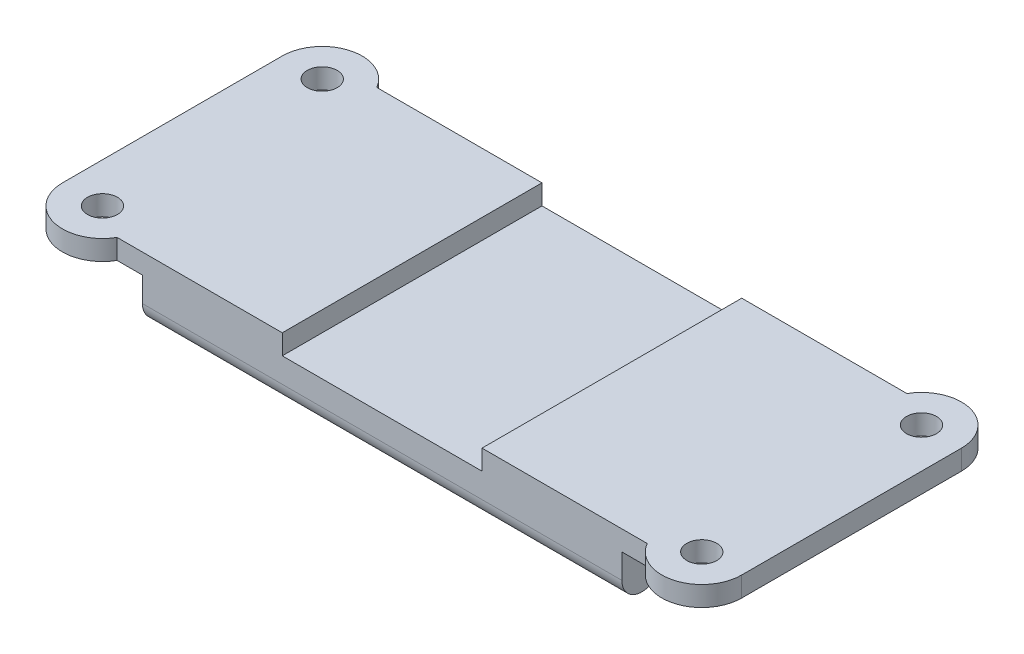
from build123d import *

# Parameters (mm, degrees)
SKETCH1_W               = 48
SKETCH1_H               = 26
BOSS_EXTRUDE1_DEPTH     = 8
CUT_EXTRUDE1_DEPTH      = 1
CUT_EXTRUDE1_DEPTH_BACK = 49
FILLET1_R               = 2
SKETCH5_W               = 26
SKETCH5_H               = 2
BOSS_EXTRUDE2_DEPTH     = 10
SKETCH6_R               = 1.5
CUT_EXTRUDE2_DEPTH      = 10
SKETCH3_W               = 10
SKETCH3_H               = 2
CUT_EXTRUDE3_DEPTH      = 27
FILLET3_R               = 2
SKETCH7_R               = 4
SKETCH7_R_2             = 1.5
BOSS_EXTRUDE3_DEPTH     = 2


with BuildPart() as part:
    # Sketch1 → Boss-Extrude1 (new body)
    with BuildSketch(Plane(origin=(0, 0, 0), x_dir=(1, 0, 0), z_dir=(0, 1, 0))):
        Rectangle(SKETCH1_W, SKETCH1_H)
    extrude(amount=-BOSS_EXTRUDE1_DEPTH)

    # Sketch2 → Cut-Extrude1 (cut, two sides)
    with BuildSketch(Plane(origin=(24, 0, 0), x_dir=(0, 0, -1), z_dir=(1, 0, 0))) as cut_extrude1_sk:
        Polygon((-8, -5), (-13, -8), (0, -8), (0, -5), align=None)
        Polygon((0, -5), (0, -8), (13, -8), (8, -5), align=None)
    extrude(amount=CUT_EXTRUDE1_DEPTH, mode=Mode.SUBTRACT)
    extrude(cut_extrude1_sk.sketch, amount=-CUT_EXTRUDE1_DEPTH_BACK, mode=Mode.SUBTRACT)

    # Fillet1
    fillet1_edges = [part.edges().sort_by_distance(p)[0] for p in [
        (0, -8, -13),
        (0, -5, 8),
        (0, -5, -8),
        (0, -8, 13),
    ]]
    fillet(fillet1_edges, radius=FILLET1_R)

    # Sketch5 → Boss-Extrude2 (add)
    with BuildSketch(Plane.ZY.offset(24)):
        with Locations((0, -1)):
            Rectangle(SKETCH5_W, SKETCH5_H)
    boss_extrude2 = extrude(amount=BOSS_EXTRUDE2_DEPTH)

    # Mirror1: Boss-Extrude2 across plane
    add(boss_extrude2.mirror(Plane(origin=(0, 0, 0), x_dir=(0, 0, 1), z_dir=(1, 0, 0))))

    # Sketch6 → Cut-Extrude2 (cut)
    with BuildSketch(Plane(origin=(0, 0, 0), x_dir=(1, 0, 0), z_dir=(0, 1, 0))):
        with Locations((-30, 11)):
            Circle(SKETCH6_R)
        with Locations((-30, -11)):
            Circle(SKETCH6_R)
        with Locations((30, -11)):
            Circle(SKETCH6_R)
        with Locations((30, 11)):
            Circle(SKETCH6_R)
    extrude(amount=-CUT_EXTRUDE2_DEPTH, mode=Mode.SUBTRACT)

    # Sketch3 → Cut-Extrude3 (cut, through all)
    with BuildSketch(Plane.XY.offset(13)):
        with Locations((5, -1)):
            Rectangle(SKETCH3_W, SKETCH3_H)
        with Locations((-5, -1)):
            Rectangle(SKETCH3_W, SKETCH3_H)
    extrude(amount=-CUT_EXTRUDE3_DEPTH, mode=Mode.SUBTRACT)

    # Fillet3
    fillet3_edges = [part.edges().sort_by_distance(p)[0] for p in [
        (-34, -1, -13),
        (-34, -1, 13),
        (34, -1, -13),
        (34, -1, 13),
    ]]
    fillet(fillet3_edges, radius=FILLET3_R)

    # Sketch7 → Boss-Extrude3 (add)
    with BuildSketch(Plane(origin=(0, 0, 0), x_dir=(1, 0, 0), z_dir=(0, 1, 0))):
        with BuildLine():
            Line((-32, 13), (-26.535898385, 13))
            ThreePointArc((-26.535898385, 13), (-31.03527618, 14.863703305), (-34, 11))
            ThreePointArc((-34, 11), (-33.414213562, 12.414213562), (-32, 13))
        make_face()
        with BuildLine():
            ThreePointArc((-34, -11), (-31.03527618, -14.863703305), (-26.535898385, -13))
            Line((-26.535898385, -13), (-32, -13))
            ThreePointArc((-32, -13), (-33.414213562, -12.414213562), (-34, -11))
        make_face()
        with Locations((30, 11)):
            Circle(SKETCH7_R)
        with Locations((30, 11)):
            Circle(SKETCH7_R_2, mode=Mode.SUBTRACT)
        with Locations((30, -11)):
            Circle(SKETCH7_R)
        with Locations((30, -11)):
            Circle(SKETCH7_R_2, mode=Mode.SUBTRACT)
    extrude(amount=-BOSS_EXTRUDE3_DEPTH)


solid = part.part
